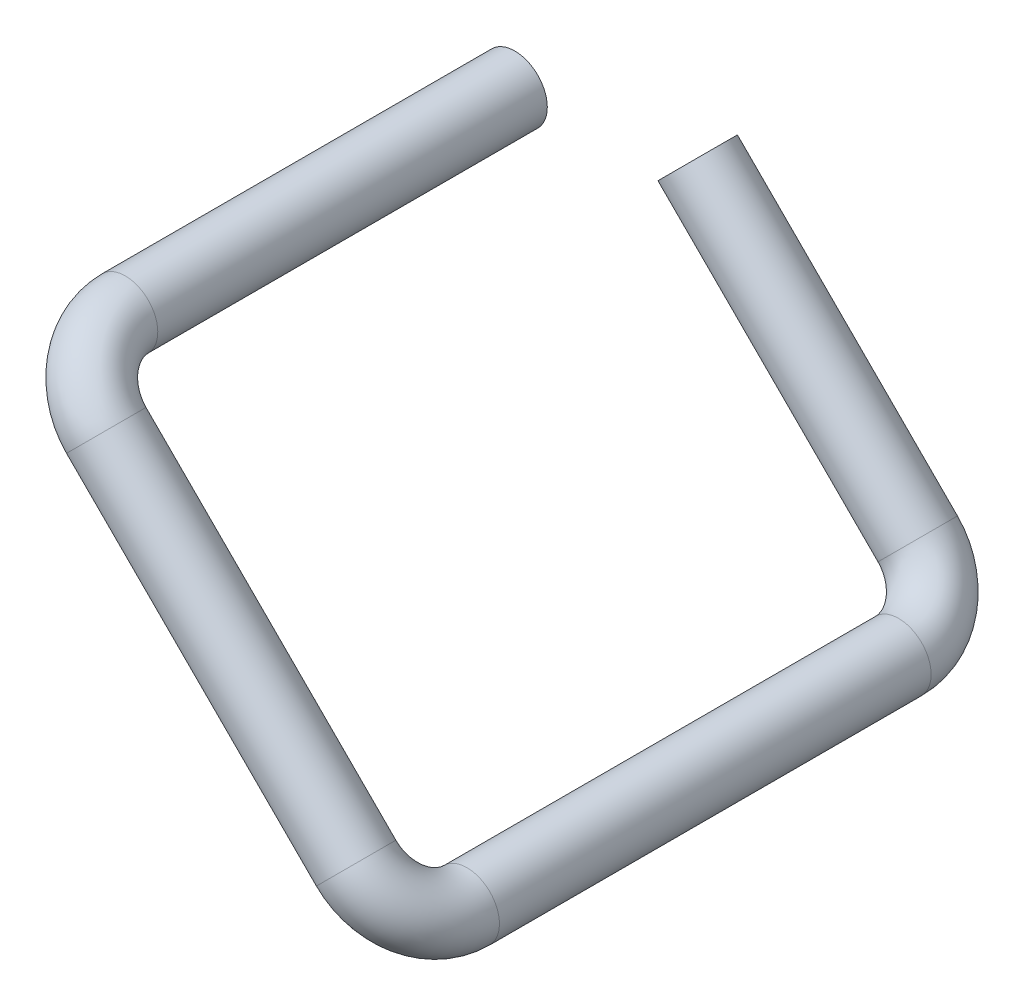
from build123d import *

# Parameters (mm, degrees)
PIPESKETCH_R   = 6.35
PIPESKETCH_R_2 = 5.842


with BuildPart() as part:
    # ThinSweep: sweep along a curve in space
    with BuildLine() as thinsweep_path:
        Line((0, 0, 0), (0, 0, 76.200357547))
        ThreePointArc((8.980256121, -8.980256121, 88.900357547), (2.630256121, -2.630256121, 85.180613669), (0, 0, 76.200357547))
        Line((8.980256121, -8.980256121, 88.900357547), (57.858111195, -57.858111195, 88.900357547))
        ThreePointArc((66.838367316, -66.838367316, 76.200357547), (64.208111195, -64.208111195, 85.180613669), (57.858111195, -57.858111195, 88.900357547))
        Line((66.838367316, -66.838367316, -8.2499), (66.838367316, -66.838367316, 76.200357547))
        ThreePointArc((57.858111195, -57.858111195, -20.9499), (64.208111195, -64.208111195, -17.230156121), (66.838367316, -66.838367316, -8.2499))
        Line((14.813816355, -14.813816355, -20.9499), (57.858111195, -57.858111195, -20.9499))
    # PipeSketch → ThinSweep (sweep)
    with BuildSketch(Plane.XY):
        Circle(PIPESKETCH_R)
        Circle(PIPESKETCH_R_2, mode=Mode.SUBTRACT)
    sweep(path=thinsweep_path.line)


solid = part.part
